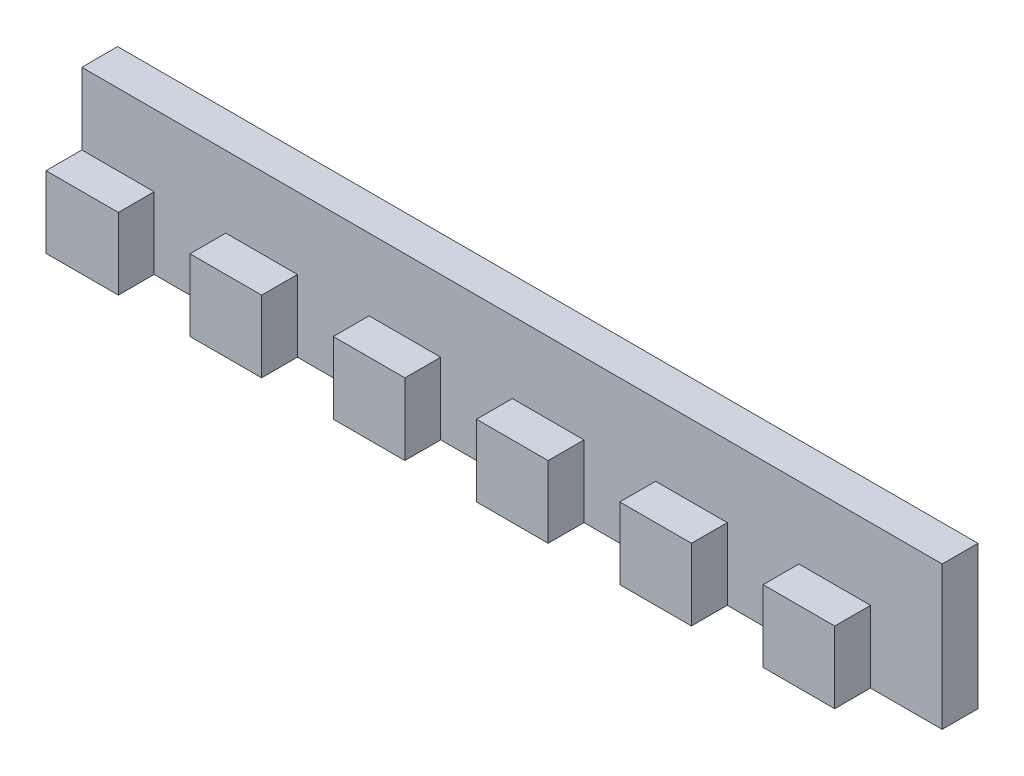
from build123d import *

# Parameters (mm, degrees)
EXTRUDE_1_DEPTH     = 20
SKETCH_2_W          = 5
SKETCH_2_H          = 10
CUT_EXTRUDE_1_DEPTH = 121.099407002


with BuildPart() as part:
    # Эскиз1 → Бобышка-Вытянуть1 (new body)
    with BuildSketch(Plane(origin=(0, 0, 0), x_dir=(1, 0, 0), z_dir=(0, 1, 0))):
        Polygon((0, 0), (10.099407002, 0), (10.099407002, 5), (20.099407002, 5), (20.099407002, 0), (30.099407002, 0), (30.099407002, 5), (40.099407002, 5), (40.099407002, 0), (50.099407002, 0), (50.099407002, 5), (60.099407002, 5), (60.099407002, 0), (70.099407002, 0), (70.099407002, 5), (80.099407002, 5), (80.099407002, 0), (90.099407002, 0), (90.099407002, 5), (100.099407002, 5), (100.099407002, 0), (110.099407002, 0), (110.099407002, 5), (120.099407002, 5), (120.099407002, 10), (0, 10), align=None)
    extrude(amount=EXTRUDE_1_DEPTH)

    # Эскиз2 → Вырез-Вытянуть1 (cut, through all)
    with BuildSketch(Plane.ZY):
        with Locations((-2.5, 15)):
            Rectangle(SKETCH_2_W, SKETCH_2_H)
    extrude(amount=-CUT_EXTRUDE_1_DEPTH, mode=Mode.SUBTRACT)


solid = part.part
